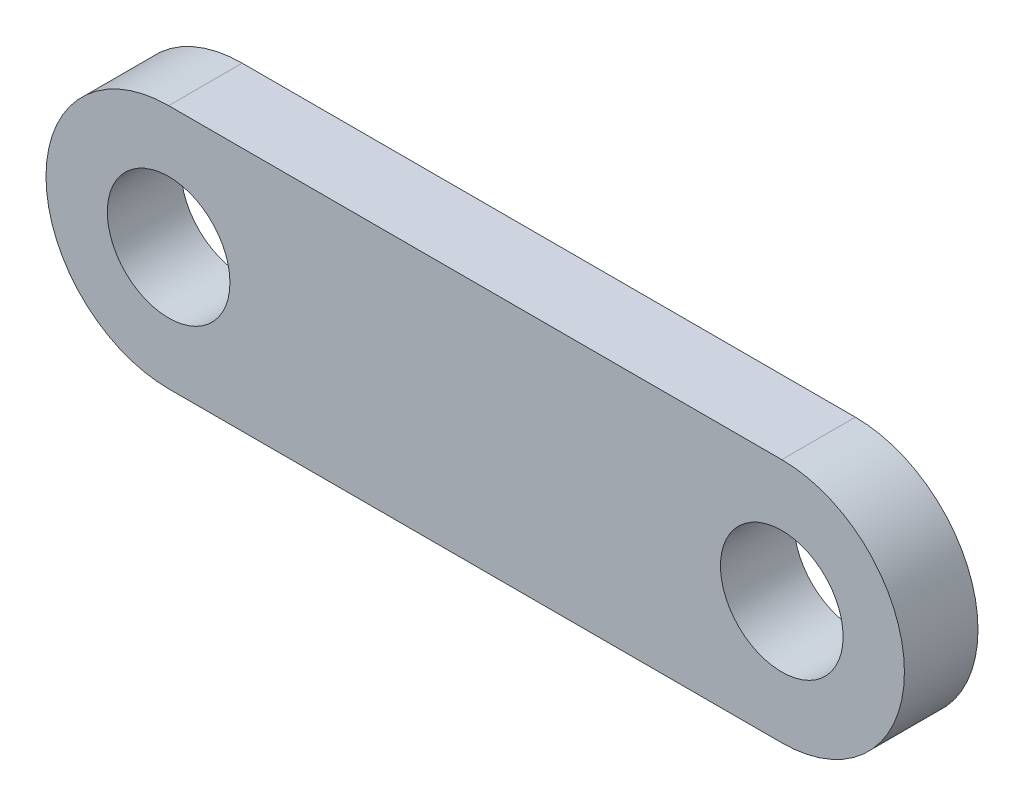
from build123d import *

# Parameters (mm, degrees)
SKETCH1_R           = 2.5
BOSS_EXTRUDE1_DEPTH = 3


with BuildPart() as part:
    # Sketch1 → Boss-Extrude1 (new body)
    with BuildSketch(Plane.XY):
        with BuildLine():
            Line((-12.5, 5), (12.5, 5))
            ThreePointArc((12.5, 5), (17.5, 0), (12.5, -5))
            Line((12.5, -5), (-12.5, -5))
            ThreePointArc((-12.5, -5), (-17.5, 0), (-12.5, 5))
        make_face()
        with Locations((12.5, 0)):
            Circle(SKETCH1_R, mode=Mode.SUBTRACT)
        with Locations((-12.5, 0)):
            Circle(SKETCH1_R, mode=Mode.SUBTRACT)
    extrude(amount=BOSS_EXTRUDE1_DEPTH)


solid = part.part
